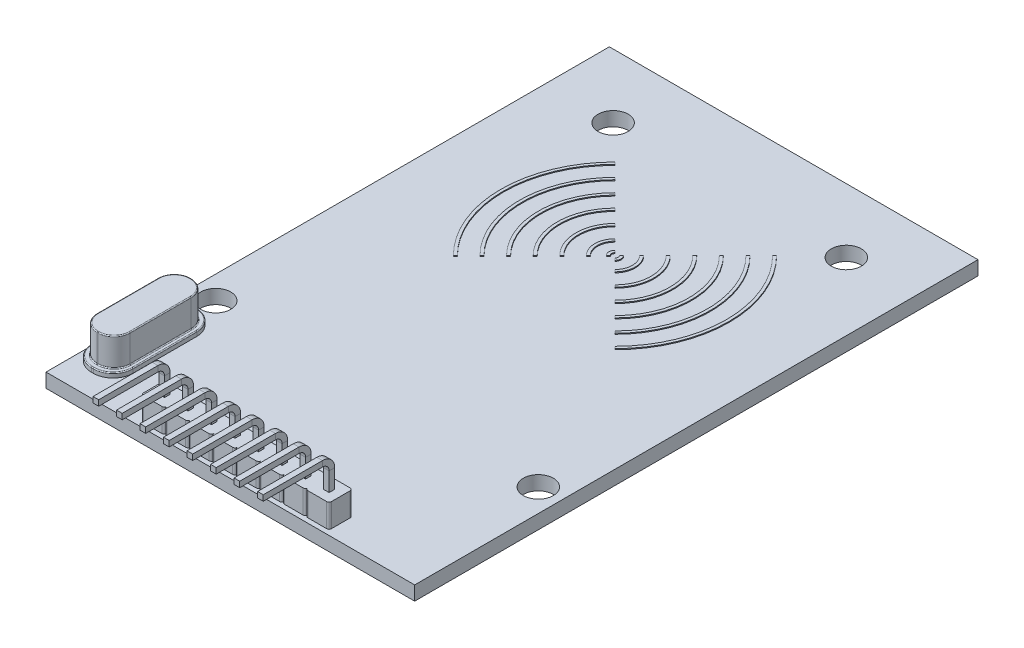
from build123d import *

# Parameters (mm, degrees)
SKETCH1_W           = 39.2
SKETCH1_H           = 59.9
BOSS_EXTRUDE1_DEPTH = 1.5
SKETCH3_R           = 1.6
CUT_EXTRUDE1_DEPTH  = 1.5
BOSS_EXTRUDE3_DEPTH = 2.5
SKETCH5_W           = 0.6
SKETCH5_H           = 0.6
CUT_EXTRUDE2_DEPTH  = 4
SKETCH6_W           = 0.6
SKETCH6_H           = 0.6
BOSS_EXTRUDE4_DEPTH = 0.5
BOSS_EXTRUDE5_DEPTH = 3
FILLET1_R           = 0.1
BOSS_EXTRUDE6_DEPTH = 0.1


with BuildPart() as part:
    # Sketch1 → Boss-Extrude1 (new body)
    with BuildSketch(Plane(origin=(0, 0, 0), x_dir=(1, 0, 0), z_dir=(0, 1, 0))):
        Rectangle(SKETCH1_W, SKETCH1_H)
    extrude(amount=BOSS_EXTRUDE1_DEPTH)

    # Sketch3 → Cut-Extrude1 (cut)
    with BuildSketch(Plane(origin=(0, 1.5, 0), x_dir=(1, 0, 0), z_dir=(0, 1, 0))):
        with Locations((12.4, 23.15)):
            Circle(SKETCH3_R)
        with Locations((-12.4, 23.15)):
            Circle(SKETCH3_R)
        with Locations((17.15, -14.35)):
            Circle(SKETCH3_R)
        with Locations((-17.15, -14.35)):
            Circle(SKETCH3_R)
    extrude(amount=-CUT_EXTRUDE1_DEPTH, mode=Mode.SUBTRACT)

    # Sketch4 → Boss-Extrude3 (add)
    with BuildSketch(Plane(origin=(0, 1.5, 0), x_dir=(1, 0, 0), z_dir=(0, 1, 0))):
        with BuildLine():
            Line((-9.75, -26.95), (-7.75, -26.95))
            ThreePointArc((-7.75, -26.95), (-7.573223305, -27.023223305), (-7.5, -27.2))
            ThreePointArc((-7.5, -27.2), (-7.426776695, -27.023223305), (-7.25, -26.95))
            Line((-7.25, -26.95), (-5.25, -26.95))
            ThreePointArc((-5.25, -26.95), (-5.073223305, -27.023223305), (-5, -27.2))
            ThreePointArc((-5, -27.2), (-4.926776695, -27.023223305), (-4.75, -26.95))
            Line((-4.75, -26.95), (-2.75, -26.95))
            ThreePointArc((-2.75, -26.95), (-2.573223305, -27.023223305), (-2.5, -27.2))
            ThreePointArc((-2.5, -27.2), (-2.426776695, -27.023223305), (-2.25, -26.95))
            Line((-2.25, -26.95), (-0.25, -26.95))
            ThreePointArc((-0.25, -26.95), (-0.073223305, -27.023223305), (0, -27.2))
            ThreePointArc((0, -27.2), (0.073223305, -27.023223305), (0.25, -26.95))
            Line((0.25, -26.95), (2.25, -26.95))
            ThreePointArc((2.25, -26.95), (2.426776695, -27.023223305), (2.5, -27.2))
            ThreePointArc((2.5, -27.2), (2.573223305, -27.023223305), (2.75, -26.95))
            Line((2.75, -26.95), (4.75, -26.95))
            ThreePointArc((4.75, -26.95), (4.926776695, -27.023223305), (5, -27.2))
            ThreePointArc((5, -27.2), (5.073223305, -27.023223305), (5.25, -26.95))
            Line((5.25, -26.95), (7.25, -26.95))
            ThreePointArc((7.25, -26.95), (7.426776695, -27.023223305), (7.5, -27.2))
            ThreePointArc((7.5, -27.2), (7.573223305, -27.023223305), (7.75, -26.95))
            Line((7.75, -26.95), (9.75, -26.95))
            ThreePointArc((9.75, -26.95), (9.926776695, -27.023223305), (10, -27.2))
            Line((10, -27.2), (10, -29.2))
            ThreePointArc((10, -29.2), (9.926776695, -29.376776695), (9.75, -29.45))
            Line((9.75, -29.45), (7.75, -29.45))
            ThreePointArc((7.75, -29.45), (7.573223305, -29.376776695), (7.5, -29.2))
            ThreePointArc((7.5, -29.2), (7.426776695, -29.376776695), (7.25, -29.45))
            Line((7.25, -29.45), (5.25, -29.45))
            ThreePointArc((5.25, -29.45), (5.073223305, -29.376776695), (5, -29.2))
            ThreePointArc((5, -29.2), (4.926776695, -29.376776695), (4.75, -29.45))
            Line((4.75, -29.45), (2.75, -29.45))
            ThreePointArc((2.75, -29.45), (2.573223305, -29.376776695), (2.5, -29.2))
            ThreePointArc((2.5, -29.2), (2.426776695, -29.376776695), (2.25, -29.45))
            Line((2.25, -29.45), (0.25, -29.45))
            ThreePointArc((0.25, -29.45), (0.073223305, -29.376776695), (0, -29.2))
            ThreePointArc((0, -29.2), (-0.073223305, -29.376776695), (-0.25, -29.45))
            Line((-0.25, -29.45), (-2.25, -29.45))
            ThreePointArc((-2.25, -29.45), (-2.426776695, -29.376776695), (-2.5, -29.2))
            ThreePointArc((-2.5, -29.2), (-2.573223305, -29.376776695), (-2.75, -29.45))
            Line((-2.75, -29.45), (-4.75, -29.45))
            ThreePointArc((-4.75, -29.45), (-4.926776695, -29.376776695), (-5, -29.2))
            ThreePointArc((-5, -29.2), (-5.073223305, -29.376776695), (-5.25, -29.45))
            Line((-5.25, -29.45), (-7.25, -29.45))
            ThreePointArc((-7.25, -29.45), (-7.426776695, -29.376776695), (-7.5, -29.2))
            ThreePointArc((-7.5, -29.2), (-7.573223305, -29.376776695), (-7.75, -29.45))
            Line((-7.75, -29.45), (-9.75, -29.45))
            ThreePointArc((-9.75, -29.45), (-9.926776695, -29.376776695), (-10, -29.2))
            Line((-10, -29.2), (-10, -27.2))
            ThreePointArc((-10, -27.2), (-9.926776695, -27.023223305), (-9.75, -26.95))
        make_face()
    extrude(amount=BOSS_EXTRUDE3_DEPTH)

    # Sketch5 → Cut-Extrude2 (cut)
    with BuildSketch(Plane(origin=(0, 4, 0), x_dir=(1, 0, 0), z_dir=(0, 1, 0))):
        with Locations((-8.75, -28.2)):
            Rectangle(SKETCH5_W, SKETCH5_H)
        with Locations((-6.25, -28.2)):
            Rectangle(SKETCH5_W, SKETCH5_H)
        with Locations((-3.75, -28.2)):
            Rectangle(SKETCH5_W, SKETCH5_H)
        with Locations((-1.25, -28.2)):
            Rectangle(SKETCH5_W, SKETCH5_H)
        with Locations((1.25, -28.2)):
            Rectangle(SKETCH5_W, SKETCH5_H)
        with Locations((3.75, -28.2)):
            Rectangle(SKETCH5_W, SKETCH5_H)
        with Locations((6.25, -28.2)):
            Rectangle(SKETCH5_W, SKETCH5_H)
        with Locations((8.75, -28.2)):
            Rectangle(SKETCH5_W, SKETCH5_H)
    extrude(amount=-CUT_EXTRUDE2_DEPTH, mode=Mode.SUBTRACT)

    # Sweep1: sweep along a path in Sketch7
    with BuildLine(Plane.ZY.offset(10)) as sweep1_path:
        Line((28.2, -1), (28.2, 6))
        ThreePointArc((28.2, 6), (28.492893219, 6.707106781), (29.2, 7))
        Line((29.2, 7), (35.5, 7))
    # Sketch6 → Sweep1 (sweep)
    with BuildSketch(Plane(origin=(0, -1, 0), x_dir=(-1, 0, 0), z_dir=(0, -1, 0))):
        with Locations((6.25, -28.2)):
            Rectangle(SKETCH6_W, SKETCH6_H)
        with Locations((8.75, -28.2)):
            Rectangle(SKETCH6_W, SKETCH6_H)
        with Locations((3.75, -28.2)):
            Rectangle(SKETCH6_W, SKETCH6_H)
        with Locations((1.25, -28.2)):
            Rectangle(SKETCH6_W, SKETCH6_H)
        with Locations((-1.25, -28.2)):
            Rectangle(SKETCH6_W, SKETCH6_H)
        with Locations((-3.75, -28.2)):
            Rectangle(SKETCH6_W, SKETCH6_H)
        with Locations((-6.25, -28.2)):
            Rectangle(SKETCH6_W, SKETCH6_H)
        with Locations((-8.75, -28.2)):
            Rectangle(SKETCH6_W, SKETCH6_H)
    sweep(path=sweep1_path.line)

    # Sketch8 → Boss-Extrude4 (add)
    with BuildSketch(Plane(origin=(0, 1.5, 0), x_dir=(1, 0, 0), z_dir=(0, 1, 0))):
        with BuildLine():
            Line((-17.160025397, -16.55), (-16.960025397, -16.55))
            ThreePointArc((-16.960025397, -16.55), (-15.475101156, -17.16507576), (-14.860025397, -18.65))
            Line((-14.860025397, -18.65), (-14.860025397, -25.45))
            ThreePointArc((-14.860025397, -25.45), (-15.475101156, -26.93492424), (-16.960025397, -27.55))
            Line((-16.960025397, -27.55), (-17.160025397, -27.55))
            ThreePointArc((-17.160025397, -27.55), (-18.644949637, -26.93492424), (-19.260025397, -25.45))
            Line((-19.260025397, -25.45), (-19.260025397, -18.65))
            ThreePointArc((-19.260025397, -18.65), (-18.644949637, -17.16507576), (-17.160025397, -16.55))
        make_face()
    extrude(amount=BOSS_EXTRUDE4_DEPTH)

    # Sketch10 → Boss-Extrude5 (add)
    with BuildSketch(Plane(origin=(0, 2, 0), x_dir=(1, 0, 0), z_dir=(0, 1, 0))):
        with BuildLine():
            Line((-17.110025397, -17.1), (-17.010025397, -17.1))
            ThreePointArc((-17.010025397, -17.1), (-15.807943869, -17.597918472), (-15.310025397, -18.8))
            Line((-15.310025397, -18.8), (-15.310025397, -25.3))
            ThreePointArc((-15.310025397, -25.3), (-15.807943869, -26.502081528), (-17.010025397, -27))
            Line((-17.010025397, -27), (-17.110025397, -27))
            ThreePointArc((-17.110025397, -27), (-18.312106925, -26.502081528), (-18.810025397, -25.3))
            Line((-18.810025397, -25.3), (-18.810025397, -18.8))
            ThreePointArc((-18.810025397, -18.8), (-18.312106925, -17.597918472), (-17.110025397, -17.1))
        make_face()
    extrude(amount=BOSS_EXTRUDE5_DEPTH)

    # Fillet1
    fillet1_edges = [part.edges().sort_by_distance(p)[0] for p in [
        (-18.644949637, 2, 26.93492424),
        (-17.060025397, 2, 27.55),
        (-15.475101156, 2, 26.93492424),
        (-14.860025397, 2, 22.05),
        (-15.475101156, 2, 17.16507576),
        (-17.060025397, 2, 16.55),
        (-18.644949637, 2, 17.16507576),
        (-19.260025397, 2, 22.05),
        (-18.312106925, 2, 26.502081528),
        (-17.060025397, 2, 27),
        (-15.807943869, 2, 26.502081528),
        (-15.310025397, 2, 22.05),
        (-15.807943869, 2, 17.597918472),
        (-17.060025397, 2, 17.1),
        (-18.312106925, 2, 17.597918472),
        (-18.810025397, 2, 22.05),
        (-18.312106925, 5, 26.502081528),
        (-17.060025397, 5, 27),
        (-15.807943869, 5, 26.502081528),
        (-15.310025397, 5, 22.05),
        (-15.807943869, 5, 17.597918472),
        (-17.060025397, 5, 17.1),
        (-18.312106925, 5, 17.597918472),
        (-18.810025397, 5, 22.05),
    ]]
    fillet(fillet1_edges, radius=FILLET1_R)

    # Sketch11 → Boss-Extrude6 (add)
    with BuildSketch(Plane(origin=(0, 1.5, 0), x_dir=(1, 0, 0), z_dir=(0, 1, 0))):
        with BuildLine():
            Line((-0.247487373, 11.197487373), (-0.459619408, 11.409619408))
            ThreePointArc((-0.459619408, 11.409619408), (-0.65, 10.95), (-0.459619408, 10.490380592))
            Line((-0.459619408, 10.490380592), (-0.247487373, 10.702512627))
            ThreePointArc((-0.247487373, 10.702512627), (-0.35, 10.95), (-0.247487373, 11.197487373))
        make_face()
        with BuildLine():
            Line((0.247487373, 11.197487373), (0.459619408, 11.409619408))
            ThreePointArc((0.459619408, 11.409619408), (0.65, 10.95), (0.459619408, 10.490380592))
            Line((0.459619408, 10.490380592), (0.247487373, 10.702512627))
            ThreePointArc((0.247487373, 10.702512627), (0.35, 10.95), (0.247487373, 11.197487373))
        make_face()
        with BuildLine():
            Line((-8.485281374, 19.435281374), (-8.591347391, 19.541347391))
            ThreePointArc((-8.591347391, 19.541347391), (-12.15, 10.95), (-8.591347391, 2.358652609))
            Line((-8.591347391, 2.358652609), (-8.485281374, 2.464718626))
            Line((-8.485281374, 2.464718626), (-8.379215357, 2.570784643))
            ThreePointArc((-8.379215357, 2.570784643), (-11.85, 10.95), (-8.379215357, 19.329215357))
            Line((-8.379215357, 19.329215357), (-8.485281374, 19.435281374))
        make_face()
        with BuildLine():
            Line((8.485281374, 2.464718626), (8.591347391, 2.358652609))
            ThreePointArc((8.591347391, 2.358652609), (12.15, 10.95), (8.591347391, 19.541347391))
            Line((8.591347391, 19.541347391), (8.485281374, 19.435281374))
            Line((8.485281374, 19.435281374), (8.379215357, 19.329215357))
            ThreePointArc((8.379215357, 19.329215357), (11.85, 10.95), (8.379215357, 2.570784643))
            Line((8.379215357, 2.570784643), (8.485281374, 2.464718626))
        make_face()
        with BuildLine():
            Line((-6.965001795, 17.915001795), (-7.177133829, 18.127133829))
            ThreePointArc((-7.177133829, 18.127133829), (-10.15, 10.95), (-7.177133829, 3.772866171))
            Line((-7.177133829, 3.772866171), (-6.965001795, 3.984998205))
            ThreePointArc((-6.965001795, 3.984998205), (-9.85, 10.95), (-6.965001795, 17.915001795))
        make_face()
        with BuildLine():
            Line((-5.550788232, 16.500788232), (-5.762920267, 16.712920267))
            ThreePointArc((-5.762920267, 16.712920267), (-8.15, 10.95), (-5.762920267, 5.187079733))
            Line((-5.762920267, 5.187079733), (-5.550788232, 5.399211768))
            ThreePointArc((-5.550788232, 5.399211768), (-7.85, 10.95), (-5.550788232, 16.500788232))
        make_face()
        with BuildLine():
            Line((-4.13657467, 15.08657467), (-4.348706704, 15.298706704))
            ThreePointArc((-4.348706704, 15.298706704), (-6.15, 10.95), (-4.348706704, 6.601293296))
            Line((-4.348706704, 6.601293296), (-4.13657467, 6.81342533))
            ThreePointArc((-4.13657467, 6.81342533), (-5.85, 10.95), (-4.13657467, 15.08657467))
        make_face()
        with BuildLine():
            Line((-2.722361108, 13.672361108), (-2.934493142, 13.884493142))
            ThreePointArc((-2.934493142, 13.884493142), (-4.15, 10.95), (-2.934493142, 8.015506858))
            Line((-2.934493142, 8.015506858), (-2.722361108, 8.227638892))
            ThreePointArc((-2.722361108, 8.227638892), (-3.85, 10.95), (-2.722361108, 13.672361108))
        make_face()
        with BuildLine():
            Line((-1.308147545, 12.258147545), (-1.52027958, 12.47027958))
            ThreePointArc((-1.52027958, 12.47027958), (-2.15, 10.95), (-1.52027958, 9.42972042))
            Line((-1.52027958, 9.42972042), (-1.308147545, 9.641852455))
            ThreePointArc((-1.308147545, 9.641852455), (-1.85, 10.95), (-1.308147545, 12.258147545))
        make_face()
        with BuildLine():
            Line((1.308147545, 9.641852455), (1.52027958, 9.42972042))
            ThreePointArc((1.52027958, 9.42972042), (2.15, 10.95), (1.52027958, 12.47027958))
            Line((1.52027958, 12.47027958), (1.308147545, 12.258147545))
            ThreePointArc((1.308147545, 12.258147545), (1.85, 10.95), (1.308147545, 9.641852455))
        make_face()
        with BuildLine():
            Line((2.722361108, 8.227638892), (2.934493142, 8.015506858))
            ThreePointArc((2.934493142, 8.015506858), (4.15, 10.95), (2.934493142, 13.884493142))
            Line((2.934493142, 13.884493142), (2.722361108, 13.672361108))
            ThreePointArc((2.722361108, 13.672361108), (3.85, 10.95), (2.722361108, 8.227638892))
        make_face()
        with BuildLine():
            Line((4.13657467, 6.81342533), (4.348706704, 6.601293296))
            ThreePointArc((4.348706704, 6.601293296), (6.15, 10.95), (4.348706704, 15.298706704))
            Line((4.348706704, 15.298706704), (4.13657467, 15.08657467))
            ThreePointArc((4.13657467, 15.08657467), (5.85, 10.95), (4.13657467, 6.81342533))
        make_face()
        with BuildLine():
            Line((5.550788232, 5.399211768), (5.762920267, 5.187079733))
            ThreePointArc((5.762920267, 5.187079733), (8.15, 10.95), (5.762920267, 16.712920267))
            Line((5.762920267, 16.712920267), (5.550788232, 16.500788232))
            ThreePointArc((5.550788232, 16.500788232), (7.85, 10.95), (5.550788232, 5.399211768))
        make_face()
        with BuildLine():
            Line((6.965001795, 3.984998205), (7.177133829, 3.772866171))
            ThreePointArc((7.177133829, 3.772866171), (10.15, 10.95), (7.177133829, 18.127133829))
            Line((7.177133829, 18.127133829), (6.965001795, 17.915001795))
            ThreePointArc((6.965001795, 17.915001795), (9.85, 10.95), (6.965001795, 3.984998205))
        make_face()
    extrude(amount=BOSS_EXTRUDE6_DEPTH)


solid = part.part
